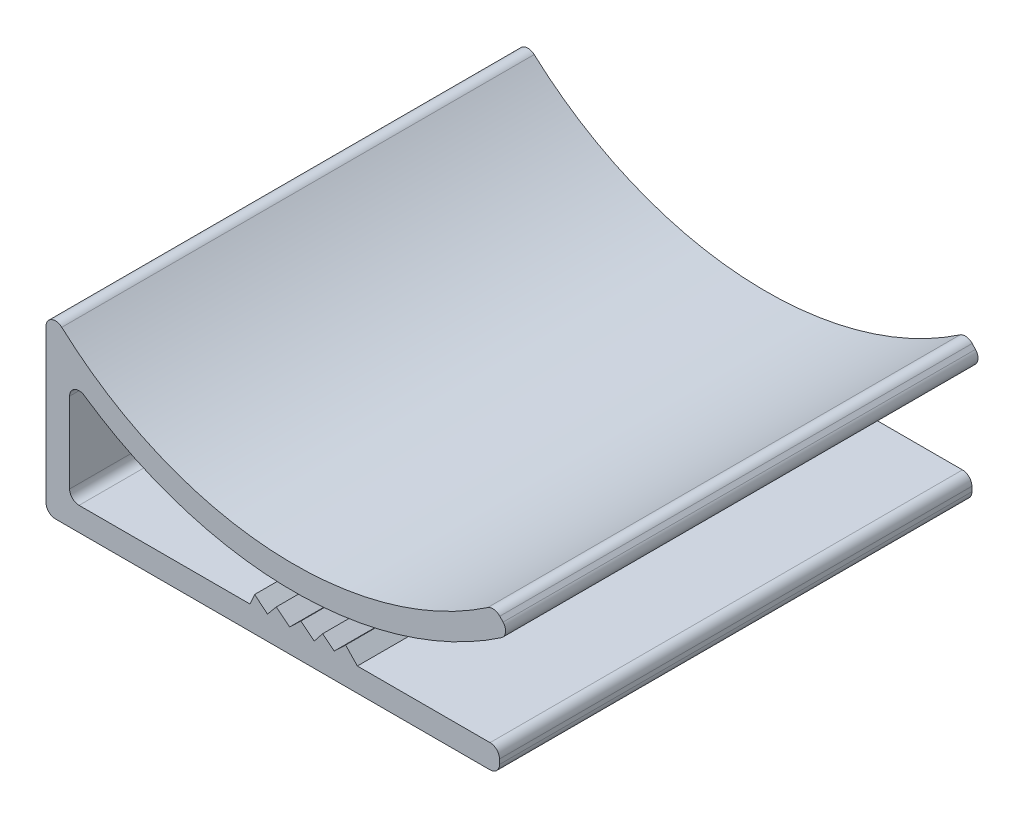
from build123d import *

# Parameters (mm, degrees)
SALIENTE_EXTRUIR1_DEPTH = 25


with BuildPart() as part:
    # Croquis1 → Saliente-Extruir1 (new body)
    with BuildSketch(Plane.XY):
        with BuildLine():
            Line((0.5, 0), (23.5, 0))
            ThreePointArc((23.5, 0), (23.853553391, 0.146446609), (24, 0.5))
            Line((24, 0.5), (24, 0.75))
            ThreePointArc((24, 0.75), (23.853553391, 1.103553391), (23.5, 1.25))
            Line((23.5, 1.25), (16.47782129, 1.25))
            Line((16.47782129, 1.25), (15.856313475, 1.900076822))
            Line((15.856313475, 1.900076822), (15.255148566, 1.325331382))
            Line((15.255148566, 1.325331382), (14.640350544, 1.812303006))
            Line((14.640350544, 1.812303006), (14.194959378, 1.25))
            Line((14.194959378, 1.25), (13.485056051, 1.812303006))
            Line((13.485056051, 1.812303006), (12.896905521, 1.25))
            Line((12.896905521, 1.25), (12.187002195, 1.812303006))
            Line((12.187002195, 1.812303006), (11.72060446, 1.25))
            Line((11.72060446, 1.25), (11.042675201, 1.812303006))
            Line((11.042675201, 1.812303006), (10.797993302, 1.25))
            Line((10.797993302, 1.25), (1.75, 1.25))
            ThreePointArc((1.75, 1.25), (1.396446609, 1.396446609), (1.25, 1.75))
            Line((1.25, 1.75), (1.25, 6.004934433))
            ThreePointArc((1.25, 6.004934433), (1.517138688, 6.44739981), (2.033102437, 6.417066706))
            ThreePointArc((2.033102437, 6.417066706), (5.924204231, 4.346635928), (10.180078199, 3.199947857))
            ThreePointArc((10.180078199, 3.199947857), (17.440764487, 3.465174135), (24.103823344, 6.361992565))
            ThreePointArc((24.103823344, 6.361992565), (24.319661393, 6.719764128), (24.188505071, 7.116481375))
            Line((24.188505071, 7.116481375), (24.015976281, 7.301546958))
            ThreePointArc((24.015976281, 7.301546958), (23.706531625, 7.457420718), (23.370061121, 7.374715069))
            ThreePointArc((23.370061121, 7.374715069), (11.830432965, 4.274140818), (0.835139338, 8.951757379))
            ThreePointArc((0.835139338, 8.951757379), (0.296984814, 9.037632425), (0, 8.580702634))
            Line((0, 8.580702634), (0, 0.5))
            ThreePointArc((0, 0.5), (0.146446609, 0.146446609), (0.5, 0))
        make_face()
    extrude(amount=SALIENTE_EXTRUIR1_DEPTH)


solid = part.part
